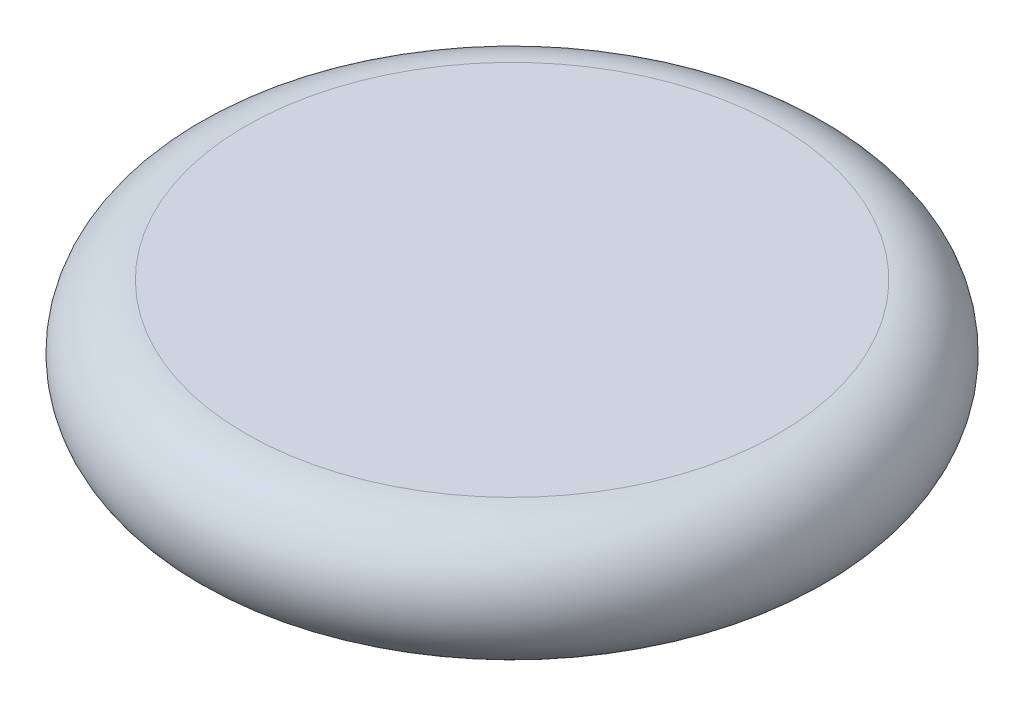
from build123d import *


with BuildPart() as part:
    # Sketch2 → Revolve1 (revolve)
    with BuildSketch(Plane.XY):
        with BuildLine():
            Line((0, 0), (40, 0))
            ThreePointArc((40, 0), (49.5, -9.5), (40, -19))
            Line((40, -19), (0, -19))
            Line((0, -19), (0, 0))
        make_face()
    revolve(axis=Axis((0, 0, 0), (0, -1, 0)))


solid = part.part
